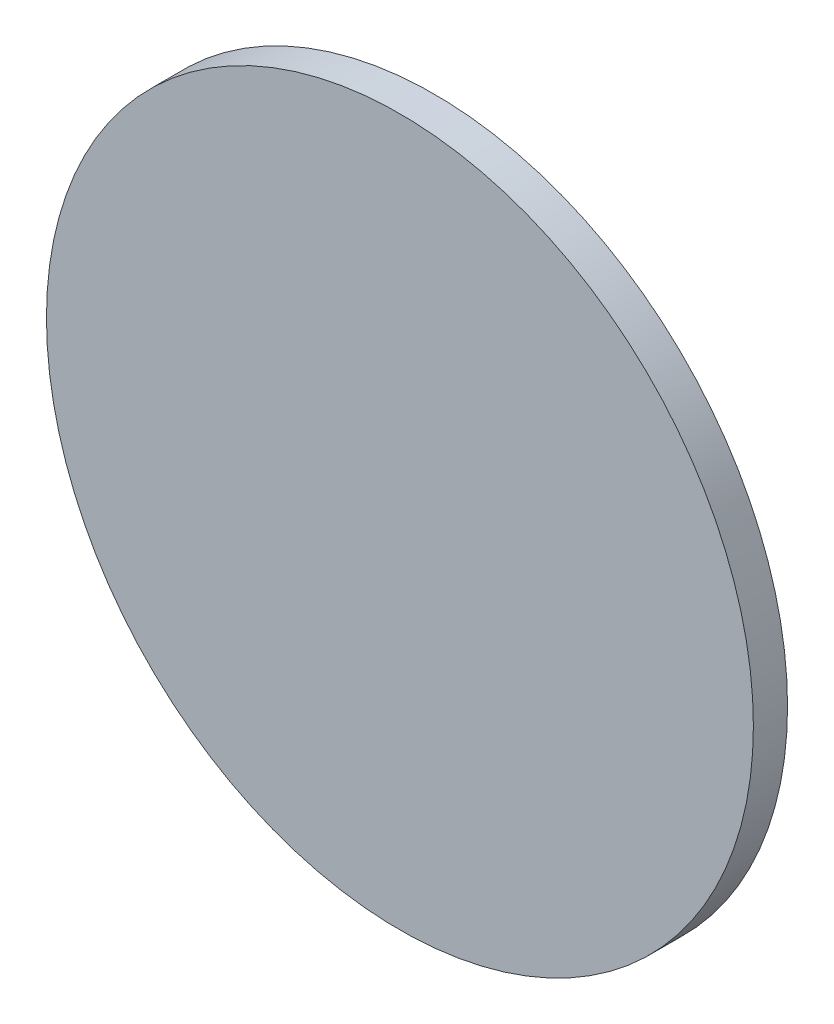
from build123d import *

# Parameters (mm, degrees)
SKETCH1_R           = 133.5
BOSS_EXTRUDE1_DEPTH = 12.9


with BuildPart() as part:
    # Sketch1 → Boss-Extrude1 (new body)
    with BuildSketch(Plane.XY):
        Circle(SKETCH1_R)
    extrude(amount=BOSS_EXTRUDE1_DEPTH)


solid = part.part
